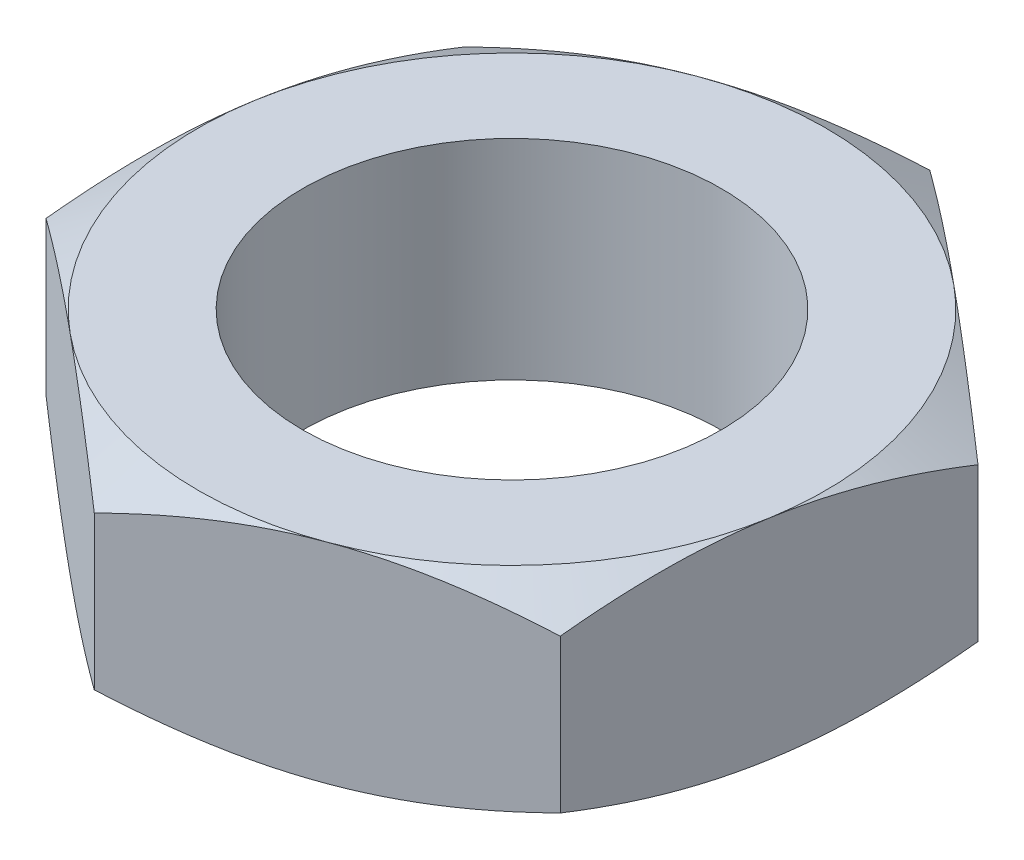
from build123d import *

# Parameters (mm, degrees)
BOSS_EXTRUDE1_DEPTH = 5
SKETCH7_OUTSIDE_W   = 26.516
SKETCH7_OUTSIDE_H   = 27.36
SKETCH7_OUTSIDE_R   = 7.5
CUT_EXTRUDE4_DEPTH  = 1
CUT_EXTRUDE4_TAPER  = 60
SKETCH8_OUTSIDE_W   = 26.516
SKETCH8_OUTSIDE_H   = 27.36
SKETCH8_OUTSIDE_R   = 7.5
CUT_EXTRUDE5_DEPTH  = 1
CUT_EXTRUDE5_TAPER  = 60
SKETCH9_R           = 5
CUT_EXTRUDE6_DEPTH  = 9


with BuildPart() as part:
    # Sketch1 → Boss-Extrude1 (new body)
    with BuildSketch(Plane(origin=(0, 0, 0), x_dir=(1, 0, 0), z_dir=(0, 1, 0))):
        Polygon((6.673205692, -5.519812116), (8.116900362, 3.019259596), (1.44369467, 8.539071712), (-6.673205692, 5.519812116), (-8.116900362, -3.019259596), (-1.44369467, -8.539071712), align=None)
    extrude(amount=BOSS_EXTRUDE1_DEPTH)

    # Sketch7 outside → Cut-Extrude4 (cut)
    with BuildSketch(Plane(origin=(0, 5, 0), x_dir=(1, 0, 0), z_dir=(0, 1, 0))):
        Rectangle(SKETCH7_OUTSIDE_W, SKETCH7_OUTSIDE_H)
        Circle(SKETCH7_OUTSIDE_R, mode=Mode.SUBTRACT)
    extrude(amount=-CUT_EXTRUDE4_DEPTH, taper=CUT_EXTRUDE4_TAPER, mode=Mode.SUBTRACT)

    # Sketch8 outside → Cut-Extrude5 (cut)
    with BuildSketch(Plane.XZ):
        Rectangle(SKETCH8_OUTSIDE_W, SKETCH8_OUTSIDE_H)
        Circle(SKETCH8_OUTSIDE_R, mode=Mode.SUBTRACT)
    extrude(amount=-CUT_EXTRUDE5_DEPTH, taper=CUT_EXTRUDE5_TAPER, mode=Mode.SUBTRACT)

    # Sketch9 → Cut-Extrude6 (cut)
    with BuildSketch(Plane(origin=(0, 5, 0), x_dir=(1, 0, 0), z_dir=(0, 1, 0))):
        Circle(SKETCH9_R)
    extrude(amount=-CUT_EXTRUDE6_DEPTH, mode=Mode.SUBTRACT)


solid = part.part
